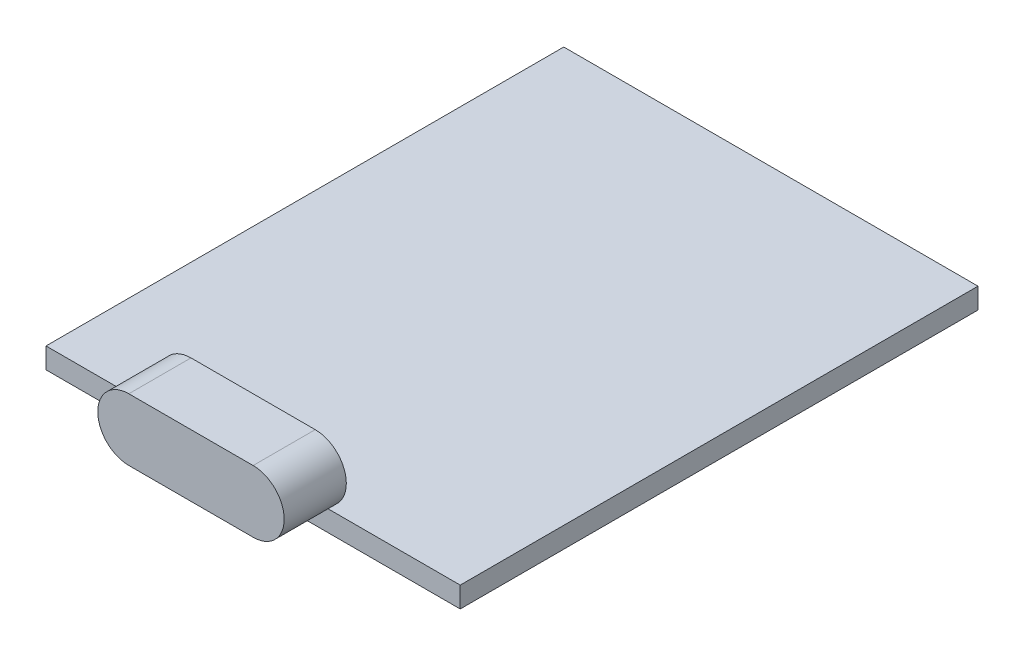
from build123d import *

# Parameters (mm, degrees)
SKETCH1_W           = 20
SKETCH1_H           = 25
BOSS_EXTRUDE1_DEPTH = 1
BOSS_EXTRUDE2_DEPTH = 3


with BuildPart() as part:
    # Sketch1 → Boss-Extrude1 (new body)
    with BuildSketch(Plane(origin=(0, 0, 0), x_dir=(1, 0, 0), z_dir=(0, 1, 0))):
        Rectangle(SKETCH1_W, SKETCH1_H)
    extrude(amount=BOSS_EXTRUDE1_DEPTH)


with BuildPart() as body_2:
    # Sketch2 → Boss-Extrude2 (new body)
    with BuildSketch(Plane.XY.offset(12.5)):
        with BuildLine():
            Line((-3, 1), (3, 1))
            ThreePointArc((3, 1), (4.5, 2.5), (3, 4))
            Line((3, 4), (-3, 4))
            ThreePointArc((-3, 4), (-4.5, 2.5), (-3, 1))
        make_face()
    extrude(amount=BOSS_EXTRUDE2_DEPTH)


solid = Compound([part.part, body_2.part])
